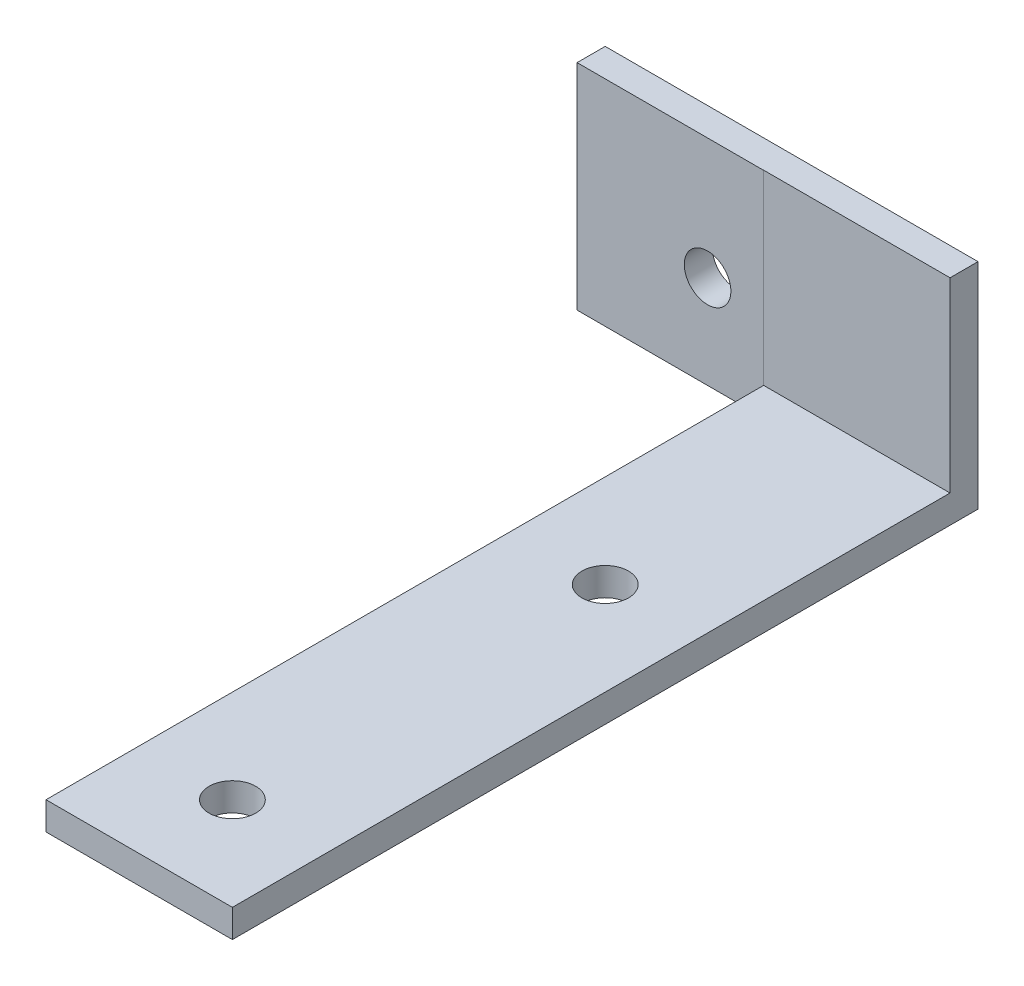
from build123d import *

# Parameters (mm, degrees)
SKETCH1_W           = 20
SKETCH1_H           = 80
SKETCH1_R           = 2.5
BOSS_EXTRUDE1_DEPTH = 3
SKETCH2_W           = 20
SKETCH2_H           = 3
BOSS_EXTRUDE2_DEPTH = 20
SKETCH4_W           = 3.015323491
SKETCH4_H           = 23
BOSS_EXTRUDE4_DEPTH = 20
SKETCH7_R           = 2.5
CUT_EXTRUDE2_DEPTH  = 20


with BuildPart() as part:
    # Sketch1 → Boss-Extrude1 (new body)
    with BuildSketch(Plane(origin=(0, 0, 0), x_dir=(1, 0, 0), z_dir=(0, 1, 0))):
        Rectangle(SKETCH1_W, SKETCH1_H)
        with Locations((0, -30)):
            Circle(SKETCH1_R, mode=Mode.SUBTRACT)
        with Locations((0, 10)):
            Circle(SKETCH1_R, mode=Mode.SUBTRACT)
    extrude(amount=BOSS_EXTRUDE1_DEPTH)

    # Sketch2 → Boss-Extrude2 (add)
    with BuildSketch(Plane(origin=(0, 3, 0), x_dir=(1, 0, 0), z_dir=(0, 1, 0))):
        with Locations((0, 38.5)):
            Rectangle(SKETCH2_W, SKETCH2_H)
    extrude(amount=BOSS_EXTRUDE2_DEPTH)

    # Sketch4 → Boss-Extrude4 (add)
    with BuildSketch(Plane.ZY.offset(10)):
        with Locations((-38.492338254, 11.5)):
            Rectangle(SKETCH4_W, SKETCH4_H)
    extrude(amount=BOSS_EXTRUDE4_DEPTH)

    # Sketch7 → Cut-Extrude2 (cut)
    with BuildSketch(Plane(origin=(0, 0, -40), x_dir=(-1, 0, 0), z_dir=(0, 0, -1))):
        with Locations((16, 10)):
            Circle(SKETCH7_R)
    extrude(amount=-CUT_EXTRUDE2_DEPTH, mode=Mode.SUBTRACT)


solid = part.part
